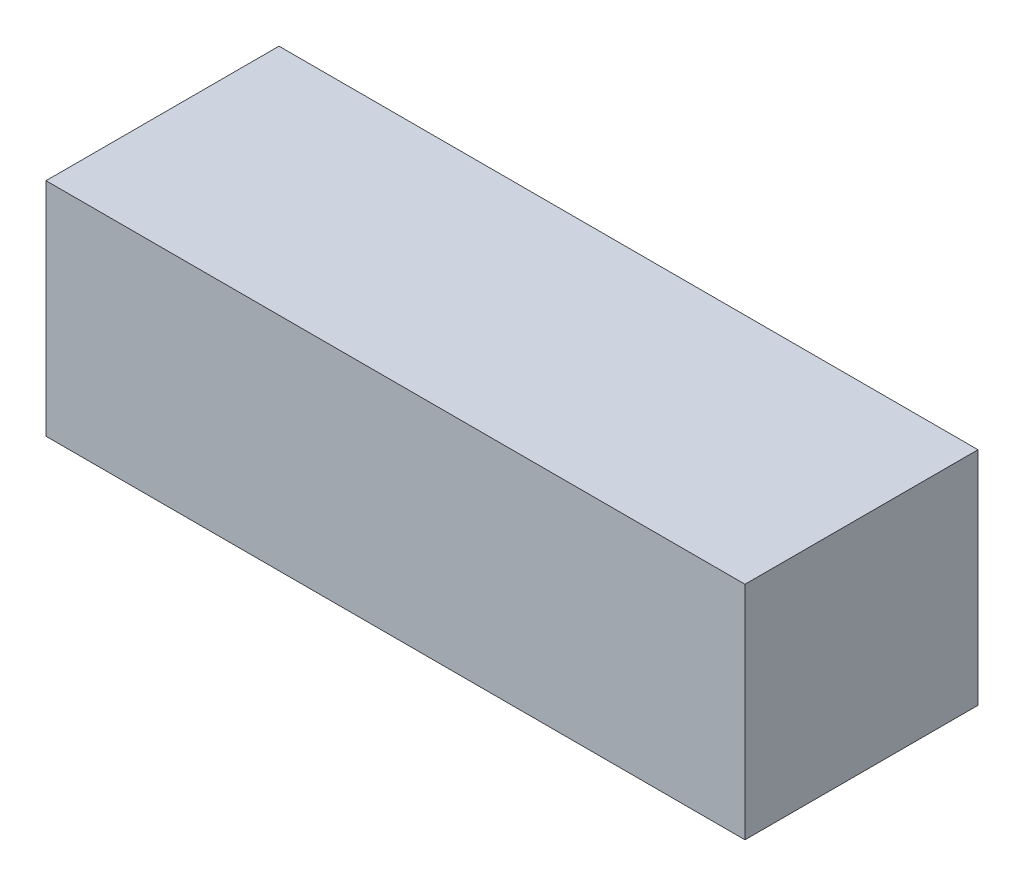
from build123d import *

# Parameters (mm, degrees)
BOSS_EXTRUDE1_DEPTH      = 14
BOSS_EXTRUDE1_DEPTH_BACK = 14
SKETCH1_W                = 110
SKETCH1_H                = 35
BOSS_EXTRUDE2_DEPTH      = 19
BOSS_EXTRUDE2_DEPTH_BACK = 19
SKETCH2_W                = 120
SKETCH2_H                = 40


with BuildPart() as part:
    # Sketch1 → Boss-Extrude1 (new, two sides: drawn at the far end of the back side and taken through both)
    with BuildSketch(Plane(origin=(0, 0, 0), x_dir=(1, 0, 0), z_dir=(0, 1, 0)).offset(-BOSS_EXTRUDE1_DEPTH_BACK)):
        Rectangle(SKETCH1_W, SKETCH1_H)
    extrude(amount=BOSS_EXTRUDE1_DEPTH + BOSS_EXTRUDE1_DEPTH_BACK)


with BuildPart() as body_2:
    # Sketch2 → Boss-Extrude2 (new, two sides: drawn at the far end of the back side and taken through both)
    with BuildSketch(Plane(origin=(0, 0, 0), x_dir=(1, 0, 0), z_dir=(0, 1, 0)).offset(-BOSS_EXTRUDE2_DEPTH_BACK)):
        with Locations((-3, 0)):
            Rectangle(SKETCH2_W, SKETCH2_H)
    extrude(amount=BOSS_EXTRUDE2_DEPTH + BOSS_EXTRUDE2_DEPTH_BACK)


solid = Compound([part.part, body_2.part])
